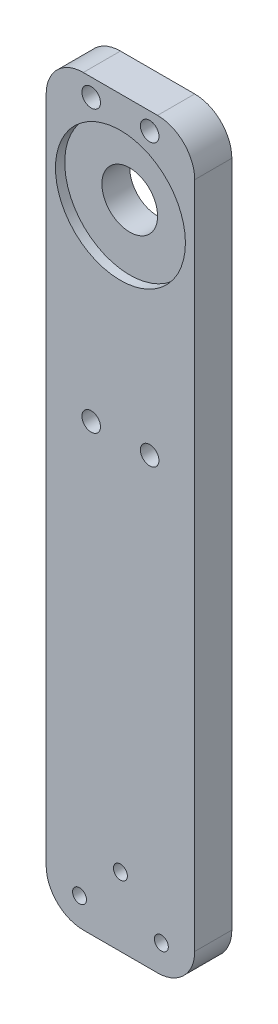
from build123d import *

# Parameters (mm, degrees)
SKETCH1_W           = 25.4
SKETCH1_H           = 127
BOSS_EXTRUDE1_DEPTH = 6.35
SKETCH2_R           = 1.190625
CUT_EXTRUDE1_DEPTH  = 6.35
FILLET1_R           = 6.35
SKETCH3_R           = 4.7625
CUT_EXTRUDE2_DEPTH  = 6.35
FILLET2_R           = 6.35
SKETCH4_R           = 11.1125
CUT_EXTRUDE3_DEPTH  = 1.5875
SKETCH5_R           = 1.5875
CUT_EXTRUDE4_DEPTH  = 6.35


with BuildPart() as part:
    # Sketch1 → Boss-Extrude1 (new body)
    with BuildSketch(Plane.XY):
        with Locations((12.7, 63.5)):
            Rectangle(SKETCH1_W, SKETCH1_H)
    extrude(amount=BOSS_EXTRUDE1_DEPTH)

    # Sketch2 → Cut-Extrude1 (cut)
    with BuildSketch(Plane.XY.offset(6.35)):
        with Locations((5.7, 4.7625)):
            Circle(SKETCH2_R)
        with Locations((19.7, 4.7625)):
            Circle(SKETCH2_R)
        with Locations((12.7, 11.7625)):
            Circle(SKETCH2_R)
    extrude(amount=-CUT_EXTRUDE1_DEPTH, mode=Mode.SUBTRACT)

    # Fillet1
    fillet1_edges = [part.edges().sort_by_distance(p)[0] for p in [
        (25.4, 0, 3.175),
        (0, 0, 3.175),
    ]]
    fillet(fillet1_edges, radius=FILLET1_R)

    # Sketch3 → Cut-Extrude2 (cut)
    with BuildSketch(Plane.XY.offset(6.35)):
        with Locations((12.7, 110.499906)):
            Circle(SKETCH3_R)
    extrude(amount=-CUT_EXTRUDE2_DEPTH, mode=Mode.SUBTRACT)

    # Fillet2
    fillet2_edges = [part.edges().sort_by_distance(p)[0] for p in [
        (0, 127, 3.175),
        (25.4, 127, 3.175),
    ]]
    fillet(fillet2_edges, radius=FILLET2_R)

    # Sketch4 → Cut-Extrude3 (cut)
    with BuildSketch(Plane.XY.offset(6.35)):
        with Locations((12.7, 110.499906)):
            Circle(SKETCH4_R)
    extrude(amount=-CUT_EXTRUDE3_DEPTH, mode=Mode.SUBTRACT)

    # Sketch5 → Cut-Extrude4 (cut)
    with BuildSketch(Plane.XY.offset(6.35)):
        with Locations((17.7, 124)):
            Circle(SKETCH5_R)
        with Locations((7.7, 124)):
            Circle(SKETCH5_R)
        with Locations((17.7, 76)):
            Circle(SKETCH5_R)
        with Locations((7.7, 76)):
            Circle(SKETCH5_R)
    extrude(amount=-CUT_EXTRUDE4_DEPTH, mode=Mode.SUBTRACT)


solid = part.part
